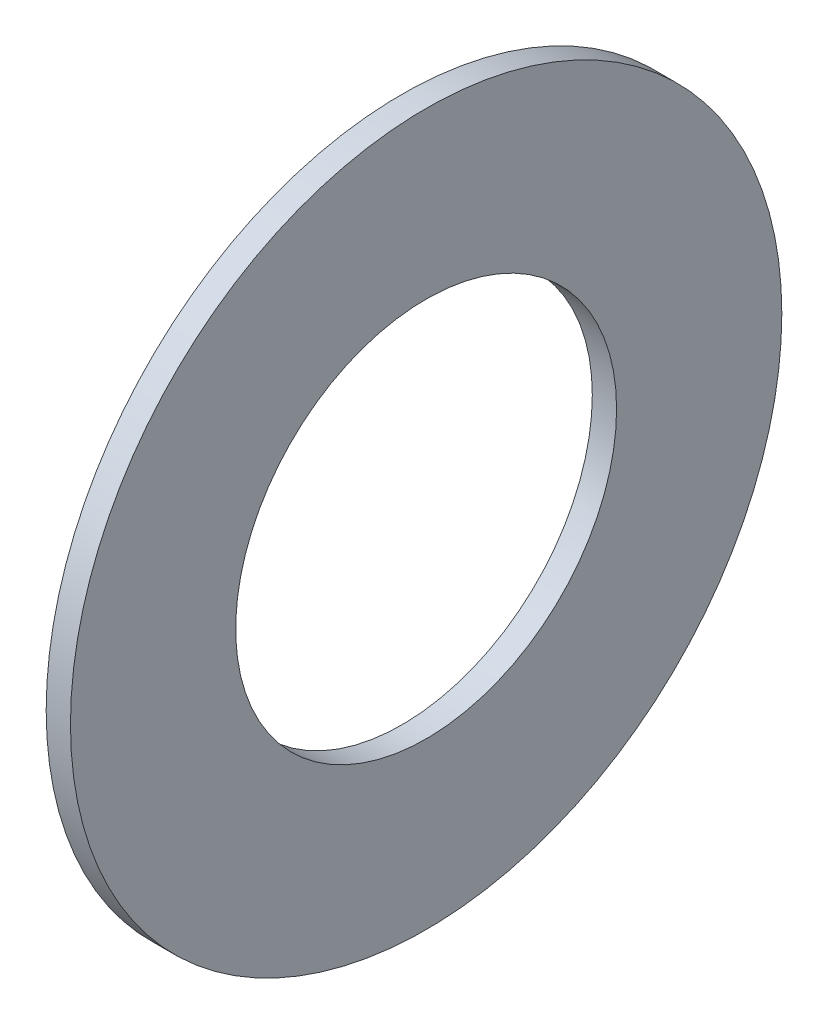
from build123d import *

# Parameters (mm, degrees)
SKETCH1_R      = 11.90625
SKETCH1_R_2    = 6.3754
EXTRUDE1_DEPTH = 0.8128


with BuildPart() as part:
    # Sketch1 → Extrude1 (new body)
    with BuildSketch(Plane(origin=(0, 0, 0), x_dir=(0, 0, -1), z_dir=(1, 0, 0))):
        Circle(SKETCH1_R)
        Circle(SKETCH1_R_2, mode=Mode.SUBTRACT)
    extrude(amount=EXTRUDE1_DEPTH)


solid = part.part
